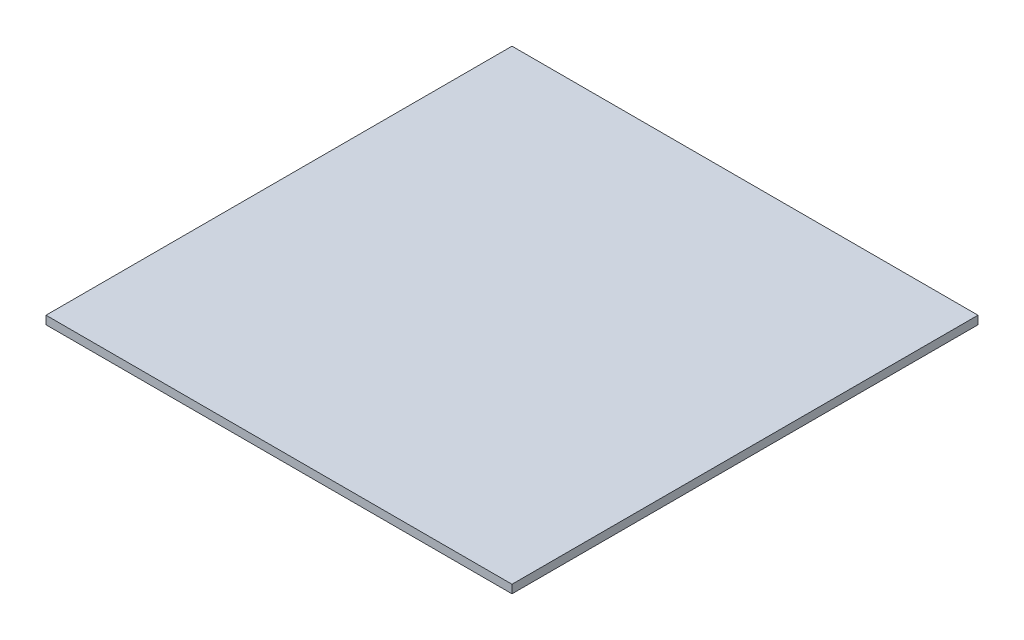
from build123d import *

# Parameters (mm, degrees)
SZKIC1_W                    = 560
SZKIC1_H                    = 560
DODANIE_WYCI_GNI_CIE2_DEPTH = 10


with BuildPart() as part:
    # Szkic1 → Dodanie-wyciągnięcie2 (new body)
    with BuildSketch(Plane(origin=(0, 0, 0), x_dir=(1, 0, 0), z_dir=(0, 1, 0))):
        Rectangle(SZKIC1_W, SZKIC1_H)
    extrude(amount=DODANIE_WYCI_GNI_CIE2_DEPTH)


solid = part.part
